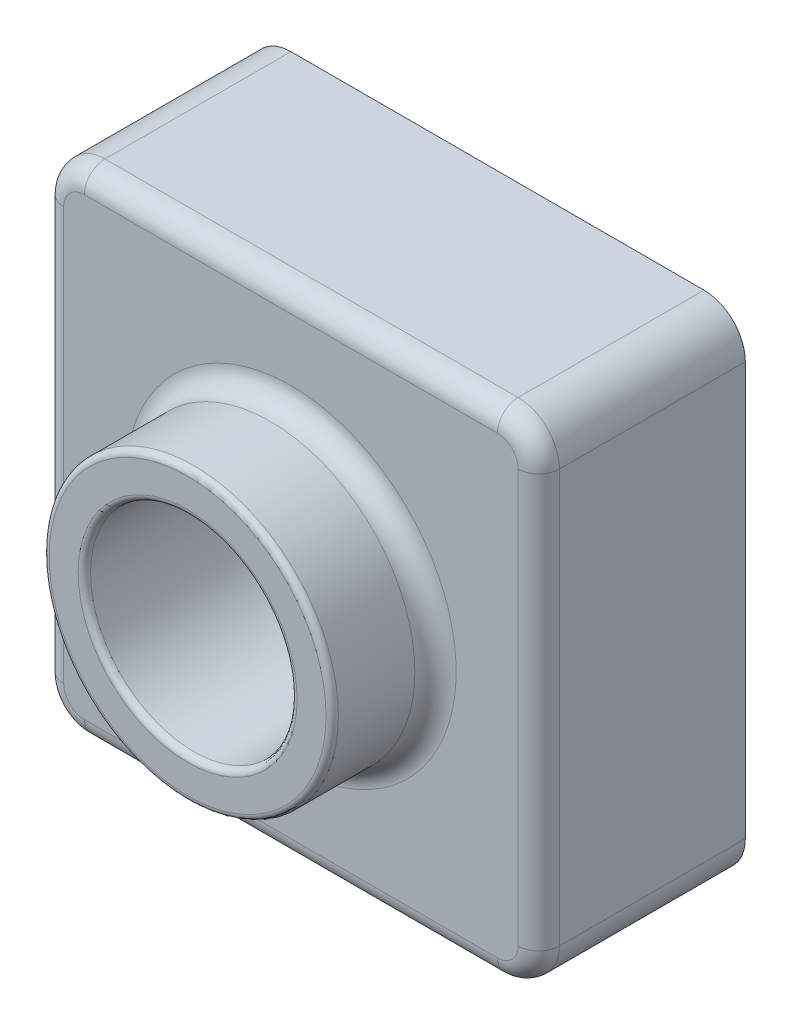
from build123d import *

# Parameters (mm, degrees)
SKETCH1_W           = 120
SKETCH1_H           = 120
BOSS_EXTRUDE1_DEPTH = 50
SKETCH3_R           = 35
BOSS_EXTRUDE2_DEPTH = 25
SKETCH4_R           = 25
CUT_EXTRUDE1_DEPTH  = 76
FILLET1_R           = 10
SHELL1_T            = -2
FILLET8_R           = 1.5
FILLET9_R           = 5


with BuildPart() as part:
    # Sketch1 → Boss-Extrude1 (new body)
    with BuildSketch(Plane.XY):
        with Locations((60, 60)):
            Rectangle(SKETCH1_W, SKETCH1_H)
    extrude(amount=BOSS_EXTRUDE1_DEPTH)

    # Sketch3 → Boss-Extrude2 (add)
    with BuildSketch(Plane.XY.offset(50)):
        with Locations((60, 60)):
            Circle(SKETCH3_R)
    extrude(amount=BOSS_EXTRUDE2_DEPTH)

    # Sketch4 → Cut-Extrude1 (cut, through all)
    with BuildSketch(Plane.XY.offset(75)):
        with Locations((60, 60)):
            Circle(SKETCH4_R)
    extrude(amount=-CUT_EXTRUDE1_DEPTH, mode=Mode.SUBTRACT)

    # Fillet1
    fillet1_edges = [part.edges().sort_by_distance(p)[0] for p in [
        (0, 120, 25),
        (120, 120, 25),
        (120, 0, 25),
        (0, 0, 25),
    ]]
    fillet(fillet1_edges, radius=FILLET1_R)

    # Shell1
    shell1_openings = [part.faces().sort_by_distance(p)[0] for p in [
        (85, 60, 0),
    ]]
    offset(amount=SHELL1_T, openings=shell1_openings, kind=Kind.INTERSECTION)

    # Fillet8
    fillet8_edges = [part.edges().sort_by_distance(p)[0] for p in [
        (25, 60, 75),
        (35, 60, 75),
    ]]
    fillet(fillet8_edges, radius=FILLET8_R)

    # Fillet9
    fillet9_edges = [part.edges().sort_by_distance(p)[0] for p in [
        (25, 60, 50),
        (60, 0, 50),
        (0, 60, 50),
        (120, 60, 50),
        (60, 120, 50),
        (117.071067812, 117.071067812, 50),
        (117.071067812, 2.928932188, 50),
        (2.928932188, 117.071067812, 50),
        (2.928932188, 2.928932188, 50),
    ]]
    fillet(fillet9_edges, radius=FILLET9_R)


solid = part.part
